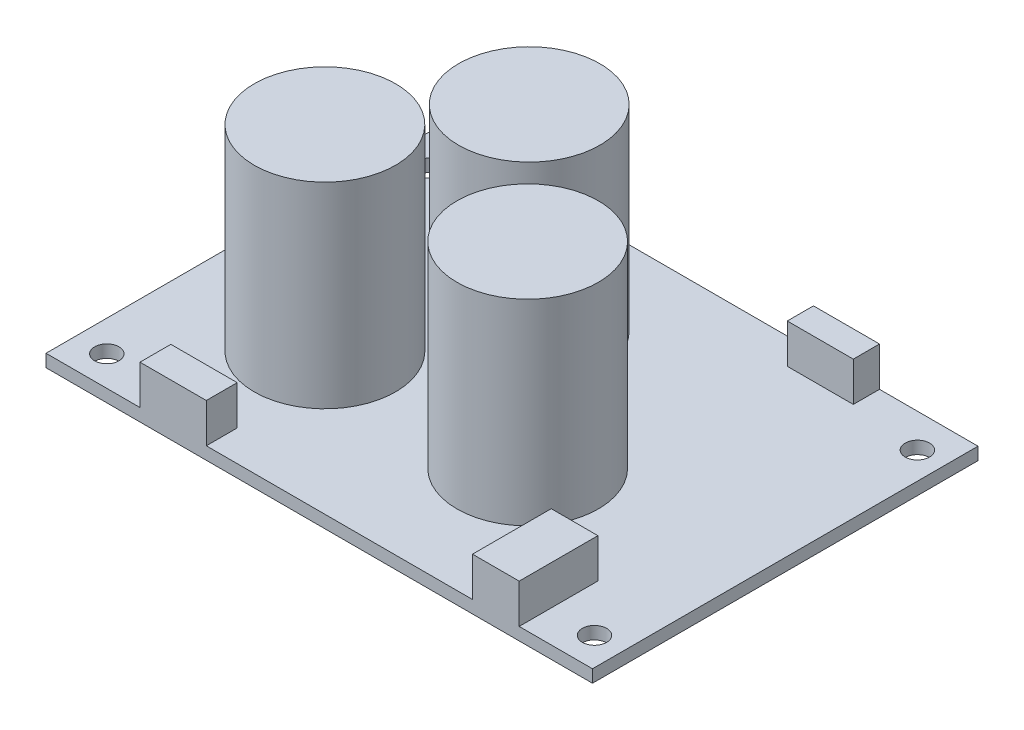
from build123d import *

# Parameters (mm, degrees)
SKETCH1_W           = 69.6
SKETCH1_H           = 49.1
BOSS_EXTRUDE1_DEPTH = 1.6
SKETCH2_R           = 9
BOSS_EXTRUDE2_DEPTH = 25
SKETCH3_R           = 1.55
CUT_EXTRUDE1_DEPTH  = 2.6
SKETCH4_W           = 7.135274134
SKETCH4_H           = 3.634808115
SKETCH4_W_2         = 8.411757442
SKETCH4_H_2         = 3.336029474
SKETCH4_W_3         = 8.448874517
SKETCH4_H_3         = 3.933927867
SKETCH4_W_4         = 5.945259598
SKETCH4_H_4         = 10.026659932
BOSS_EXTRUDE3_DEPTH = 5


with BuildPart() as part:
    # Sketch1 → Boss-Extrude1 (new body)
    with BuildSketch(Plane(origin=(0, 0, 0), x_dir=(1, 0, 0), z_dir=(0, 1, 0))):
        with Locations((34.8, -24.55)):
            Rectangle(SKETCH1_W, SKETCH1_H)
    extrude(amount=BOSS_EXTRUDE1_DEPTH)

    # Sketch2 → Boss-Extrude2 (add)
    with BuildSketch(Plane(origin=(0, 1.6, 0), x_dir=(1, 0, 0), z_dir=(0, 1, 0))):
        with Locations((17.528795591, -31.108165605)):
            Circle(SKETCH2_R)
        with Locations((28.327813128, -15.884294945)):
            Circle(SKETCH2_R)
        with Locations((43.352916856, -31.108165605)):
            Circle(SKETCH2_R)
    extrude(amount=BOSS_EXTRUDE2_DEPTH)

    # Sketch3 → Cut-Extrude1 (cut, through all)
    with BuildSketch(Plane(origin=(0, 1.6, 0), x_dir=(1, 0, 0), z_dir=(0, 1, 0))):
        with Locations((3.937, -4.318)):
            Circle(SKETCH3_R)
        with Locations((66.17, -4.29)):
            Circle(SKETCH3_R)
        with Locations((66.044, -45.29)):
            Circle(SKETCH3_R)
        with Locations((3.937, -45.29)):
            Circle(SKETCH3_R)
    extrude(amount=-CUT_EXTRUDE1_DEPTH, mode=Mode.SUBTRACT)

    # Sketch4 → Boss-Extrude3 (add)
    with BuildSketch(Plane(origin=(0, 1.6, 0), x_dir=(1, 0, 0), z_dir=(0, 1, 0))):
        with Locations((17.346192507, -1.817404058)):
            Rectangle(SKETCH4_W, SKETCH4_H)
        with Locations((52.850279958, -1.668014737)):
            Rectangle(SKETCH4_W_2, SKETCH4_H_2)
        with Locations((16.192473292, -47.133036066)):
            Rectangle(SKETCH4_W_3, SKETCH4_H_3)
        with Locations((57.291981259, -44.086670034)):
            Rectangle(SKETCH4_W_4, SKETCH4_H_4)
    extrude(amount=BOSS_EXTRUDE3_DEPTH)


solid = part.part
